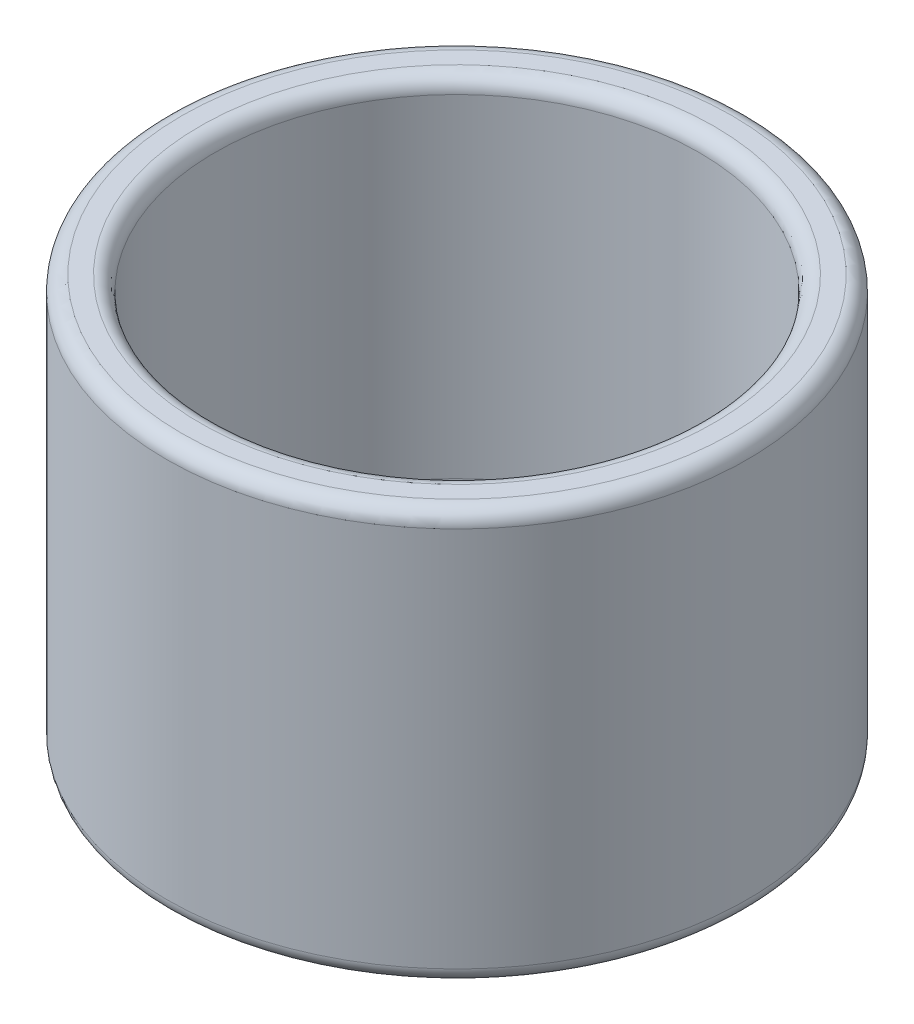
from build123d import *

# Parameters (mm, degrees)
FILLET1_R = 0.79375


with BuildPart() as part:
    # Sketch1 → Revolve1 (revolve)
    with BuildSketch(Plane.XY):
        Polygon((-15.24, 21.59), (-15.24, 0), (0, 0), (0, 2.54), (-12.7, 2.54), (-12.7, 21.59), align=None)
    revolve(axis=Axis((0, 0, 0), (0, 1, 0)))

    # Fillet1
    fillet1_edges = [part.edges().sort_by_distance(p)[0] for p in [
        (12.7, 21.59, 0),
        (12.7, 2.54, 0),
        (15.24, 0, 0),
        (15.24, 21.59, 0),
    ]]
    fillet(fillet1_edges, radius=FILLET1_R)

    # Sketch4 → CSK for #10 Flat Head Machine Screw (100)1 (revolve, cut)
    with BuildSketch(Plane(origin=(0, 2.54, 0), x_dir=(0, 0, 1), z_dir=(1, 0, 0))):
        Polygon((0, 0), (0, 2.54), (2.5527, 2.54), (2.5527, 1.960808018), (4.8895, 0), align=None)
    revolve(axis=Axis((0, 8.89, 0), (0, -1, 0)), mode=Mode.SUBTRACT)


solid = part.part
